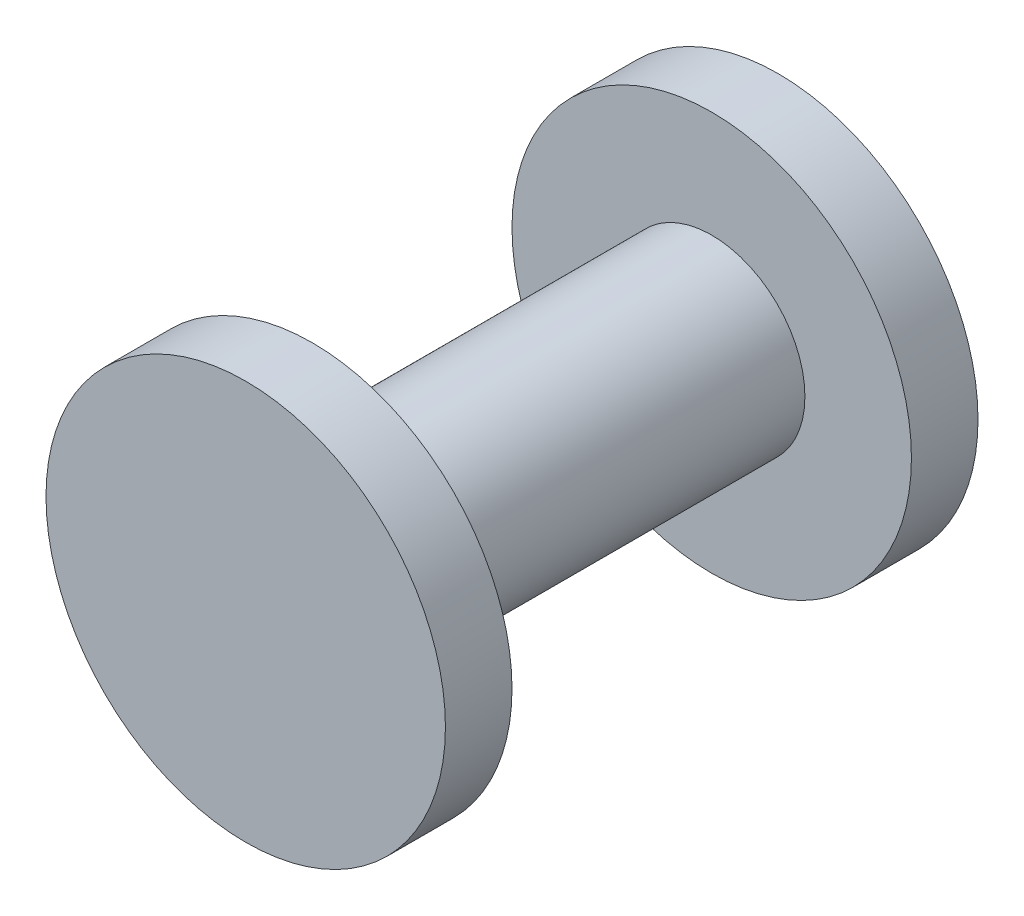
from build123d import *

# Parameters (mm, degrees)
SKETCH_1_R           = 30
SKETCH_1_R_2         = 14
EXTRUDE_1_DEPTH      = 10
SKETCH_2_R           = 14
EXTRUDE_2_DEPTH      = 70
EXTRUDE_2_DEPTH_BACK = 10
SKETCH_3_R           = 30
SKETCH_3_R_2         = 14
EXTRUDE_3_DEPTH      = 10


with BuildPart() as part:
    # 草图1 → 凸台-拉伸1 (new body)
    with BuildSketch(Plane.XY):
        Circle(SKETCH_1_R)
        Circle(SKETCH_1_R_2, mode=Mode.SUBTRACT)
    extrude(amount=EXTRUDE_1_DEPTH)

    # 草图2 → 凸台-拉伸2 (add, two sides)
    with BuildSketch(Plane.XY.offset(10)) as extrude_2_sk:
        Circle(SKETCH_2_R)
    extrude(amount=EXTRUDE_2_DEPTH)
    extrude(extrude_2_sk.sketch, amount=-EXTRUDE_2_DEPTH_BACK)

    # 草图3 → 凸台-拉伸3 (add)
    with BuildSketch(Plane.XY.offset(80)):
        Circle(SKETCH_3_R)
        Circle(SKETCH_3_R_2, mode=Mode.SUBTRACT)
    extrude(amount=-EXTRUDE_3_DEPTH)


solid = part.part
